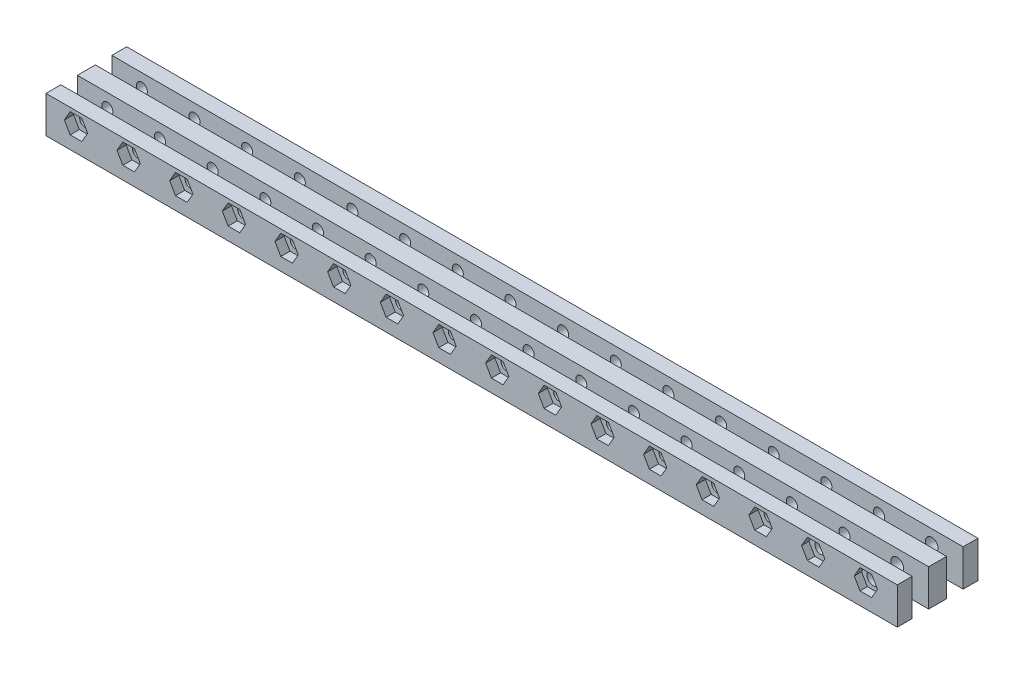
from build123d import *

# Parameters (mm, degrees)
SKETCH1_W           = 235
SKETCH1_H           = 22
BOSS_EXTRUDE1_DEPTH = 10
SKETCH2_W           = 235
SKETCH2_H           = 4.5
CUT_EXTRUDE1_DEPTH  = 6
CUT_EXTRUDE3_DEPTH  = 2.5
SKETCH9_R           = 1.5
CUT_EXTRUDE4_DEPTH  = 23
SKETCH_3_R          = 1.5
SKETCH_3_R_2        = 1.50188727
SKETCH_3_R_3        = 1.716965945
CUT_EXTRUDE_1_DEPTH = 23
CUT_EXTRUDE_2_DEPTH = 2
SKETCH_6_W          = 35
SKETCH_6_H          = 4.5
CUT_EXTRUDE_3_DEPTH = 5
SKETCH_9_W          = 3
SKETCH_9_H          = 22
CUT_EXTRUDE_4_DEPTH = 11


with BuildPart() as part:
    # Sketch1 → Boss-Extrude1 (new body)
    with BuildSketch(Plane(origin=(0, 0, 0), x_dir=(1, 0, 0), z_dir=(0, 1, 0))):
        Rectangle(SKETCH1_W, SKETCH1_H)
    extrude(amount=BOSS_EXTRUDE1_DEPTH)

    # Sketch2 → Cut-Extrude1 (cut)
    with BuildSketch(Plane(origin=(0, 10, 0), x_dir=(1, 0, 0), z_dir=(0, 1, 0))):
        with Locations((0, -4.700418011)):
            Rectangle(SKETCH2_W, SKETCH2_H)
        with Locations((0, 4.700418011)):
            Rectangle(SKETCH2_W, SKETCH2_H)
    extrude(amount=-CUT_EXTRUDE1_DEPTH, mode=Mode.SUBTRACT)

    # Sketch3 → Cut-Extrude3 (cut)
    with BuildSketch(Plane.XY.offset(11)):
        Polygon((-103.149147039, 6.25), (-104.736860279, 9), (-107.91228676, 9), (-109.5, 6.25), (-107.91228676, 3.5), (-104.736860279, 3.5), align=None)
        Polygon((-95.149147039, 6.25), (-93.561433799, 9), (-90.386007318, 9), (-88.798294078, 6.25), (-90.386007318, 3.5), (-93.561433799, 3.5), align=None)
        Polygon((-76.035154357, 9), (-79.210580838, 9), (-80.798294078, 6.25), (-79.210580838, 3.5), (-76.035154357, 3.5), (-74.447441117, 6.25), align=None)
        Polygon((-64.859727876, 3.5), (-66.447441117, 6.25), (-64.859727876, 9), (-61.684301396, 9), (-60.096588156, 6.25), (-61.684301396, 3.5), align=None)
        Polygon((-47.333448435, 9), (-50.508874915, 9), (-52.096588156, 6.25), (-50.508874915, 3.5), (-47.333448435, 3.5), (-45.745735195, 6.25), align=None)
        Polygon((-36.158021954, 3.5), (-37.745735195, 6.25), (-36.158021954, 9), (-32.982595474, 9), (-31.394882233, 6.25), (-32.982595474, 3.5), align=None)
        Polygon((-17.044029272, 6.25), (-18.631742513, 9), (-21.807168993, 9), (-23.394882233, 6.25), (-21.807168993, 3.5), (-18.631742513, 3.5), align=None)
        Polygon((-9.044029272, 6.25), (-7.456316032, 9), (-4.280889552, 9), (-2.693176311, 6.25), (-4.280889552, 3.5), (-7.456316032, 3.5), align=None)
        Polygon((10.06996341, 9), (6.894536929, 9), (5.306823689, 6.25), (6.894536929, 3.5), (10.06996341, 3.5), (11.65767665, 6.25), align=None)
        Polygon((21.24538989, 3.5), (19.65767665, 6.25), (21.24538989, 9), (24.420816371, 9), (26.008529611, 6.25), (24.420816371, 3.5), align=None)
        Polygon((38.771669332, 9), (35.596242851, 9), (34.008529611, 6.25), (35.596242851, 3.5), (38.771669332, 3.5), (40.359382572, 6.25), align=None)
        Polygon((49.947095812, 3.5), (48.359382572, 6.25), (49.947095812, 9), (53.122522293, 9), (54.710235533, 6.25), (53.122522293, 3.5), align=None)
        Polygon((69.061088494, 6.25), (67.473375254, 9), (64.297948773, 9), (62.710235533, 6.25), (64.297948773, 3.5), (67.473375254, 3.5), align=None)
        Polygon((77.061088494, 6.25), (78.648801734, 9), (81.824228215, 9), (83.411941455, 6.25), (81.824228215, 3.5), (78.648801734, 3.5), align=None)
    extrude(amount=-CUT_EXTRUDE3_DEPTH, mode=Mode.SUBTRACT)

    # Sketch9 → Cut-Extrude4 (cut, through all)
    with BuildSketch(Plane.XY.offset(11)):
        with Locations((-106.324573519, 6.25)):
            Circle(SKETCH9_R)
        with Locations((-91.973720558, 6.25)):
            Circle(SKETCH9_R)
        with Locations((-77.622867597, 6.25)):
            Circle(SKETCH9_R)
        with Locations((-63.272014636, 6.25)):
            Circle(SKETCH9_R)
        with Locations((-48.921161675, 6.25)):
            Circle(SKETCH9_R)
        with Locations((-34.570308714, 6.25)):
            Circle(SKETCH9_R)
        with Locations((-20.219455753, 6.25)):
            Circle(SKETCH9_R)
        with Locations((-5.868602792, 6.25)):
            Circle(SKETCH9_R)
        with Locations((8.482250169, 6.25)):
            Circle(SKETCH9_R)
        with Locations((22.83310313, 6.25)):
            Circle(SKETCH9_R)
        with Locations((37.183956091, 6.25)):
            Circle(SKETCH9_R)
        with Locations((51.534809052, 6.25)):
            Circle(SKETCH9_R)
        with Locations((65.885662014, 6.25)):
            Circle(SKETCH9_R)
        with Locations((80.236514975, 6.25)):
            Circle(SKETCH9_R)
    extrude(amount=-CUT_EXTRUDE4_DEPTH, mode=Mode.SUBTRACT)

    # 草图3 → 切除-拉伸1 (cut, through all)
    with BuildSketch(Plane.XY.offset(11)):
        with Locations((80.236514975, 6.25)):
            Circle(SKETCH_3_R)
        with Locations((94.586514975, 6.25)):
            Circle(SKETCH_3_R_2)
        with Locations((108.936514975, 6.25)):
            Circle(SKETCH_3_R_3)
        with Locations((65.885662014, 6.25)):
            Circle(SKETCH_3_R)
    extrude(amount=-CUT_EXTRUDE_1_DEPTH, mode=Mode.SUBTRACT)

    # 草图4 → 切除-拉伸2 (cut)
    with BuildSketch(Plane.XY.offset(11)):
        Polygon((81.824228215, 3.5), (83.411941455, 6.25), (81.824228215, 9), (78.648801734, 9), (77.061088494, 6.25), (78.648801734, 3.5), align=None)
        Polygon((97.761941455, 6.25), (96.174228215, 9), (92.998801734, 9), (91.411088494, 6.25), (92.998801734, 3.5), (96.174228215, 3.5), align=None)
        Polygon((112.111941455, 6.25), (110.524228215, 9), (107.348801734, 9), (105.761088494, 6.25), (107.348801734, 3.5), (110.524228215, 3.5), align=None)
    extrude(amount=-CUT_EXTRUDE_2_DEPTH, mode=Mode.SUBTRACT)

    # 草图6 → 切除-拉伸3 (cut, through all)
    with BuildSketch(Plane(origin=(0, 4, 0), x_dir=(1, 0, 0), z_dir=(0, 1, 0))):
        with Locations((100, -4.700418011)):
            Rectangle(SKETCH_6_W, SKETCH_6_H)
        with Locations((100, 4.700418011)):
            Rectangle(SKETCH_6_W, SKETCH_6_H)
        with Locations((-100, -4.700418011)):
            Rectangle(SKETCH_6_W, SKETCH_6_H)
        with Locations((-100, 4.700418011)):
            Rectangle(SKETCH_6_W, SKETCH_6_H)
    extrude(amount=-CUT_EXTRUDE_3_DEPTH, mode=Mode.SUBTRACT)

    # 草图9 → 切除-拉伸4 (cut, through all)
    with BuildSketch(Plane(origin=(0, 10, 0), x_dir=(1, 0, 0), z_dir=(0, 1, 0))):
        with Locations((-116, 0)):
            Rectangle(SKETCH_9_W, SKETCH_9_H)
    extrude(amount=-CUT_EXTRUDE_4_DEPTH, mode=Mode.SUBTRACT)


solid = part.part
